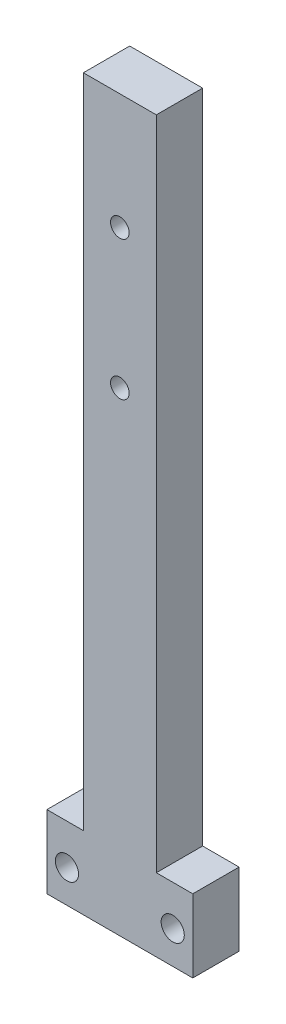
from build123d import *

# Parameters (mm, degrees)
BOSS_EXTRUDE1_DEPTH               = 12.7
F_1_4_20_TAPPED_HOLE1_D           = 5.1054
F_1_4_20_TAPPED_HOLE1_CSINK_D     = 7.62
F_1_4_20_TAPPED_HOLE1_CSINK_ANGLE = 100
F_1_4_0_25_DIAMETER_HOLE1_D       = 6.35
F_1_4_0_25_DIAMETER_HOLE1_DEPTH   = 19.05
F_1_4_0_25_DIAMETER_HOLE1_TIP     = 1.907732465


with BuildPart() as part:
    # Sketch1 → Boss-Extrude1 (new body)
    with BuildSketch(Plane.XY):
        Polygon((-20, 0), (20, 0), (20, 20), (10, 20), (10, 200), (-10, 200), (-10, 20), (-20, 20), align=None)
    extrude(amount=BOSS_EXTRUDE1_DEPTH)

    # 1/4-20 Tapped Hole1 (through all)
    with Locations(Plane(origin=(0, 0, 0), x_dir=(-1, 0, 0), z_dir=(0, 0, -1))):
        with Locations((0, 168.25), (0, 130.15)):
            CounterSinkHole(F_1_4_20_TAPPED_HOLE1_D / 2, F_1_4_20_TAPPED_HOLE1_CSINK_D / 2, counter_sink_angle=F_1_4_20_TAPPED_HOLE1_CSINK_ANGLE)

    # 1/4 (0.25) Diameter Hole1
    with Locations(Plane(origin=(0, 0, 0), x_dir=(-1, 0, 0), z_dir=(0, 0, -1))):
        with Locations((14.5, 9), (-14.5, 9)):
            Hole(F_1_4_0_25_DIAMETER_HOLE1_D / 2, depth=F_1_4_0_25_DIAMETER_HOLE1_DEPTH)
            with Locations((0, 0, -(F_1_4_0_25_DIAMETER_HOLE1_DEPTH + F_1_4_0_25_DIAMETER_HOLE1_TIP / 2))):  # 118° drill point
                Cone(0, F_1_4_0_25_DIAMETER_HOLE1_D / 2, F_1_4_0_25_DIAMETER_HOLE1_TIP, mode=Mode.SUBTRACT)


solid = part.part
